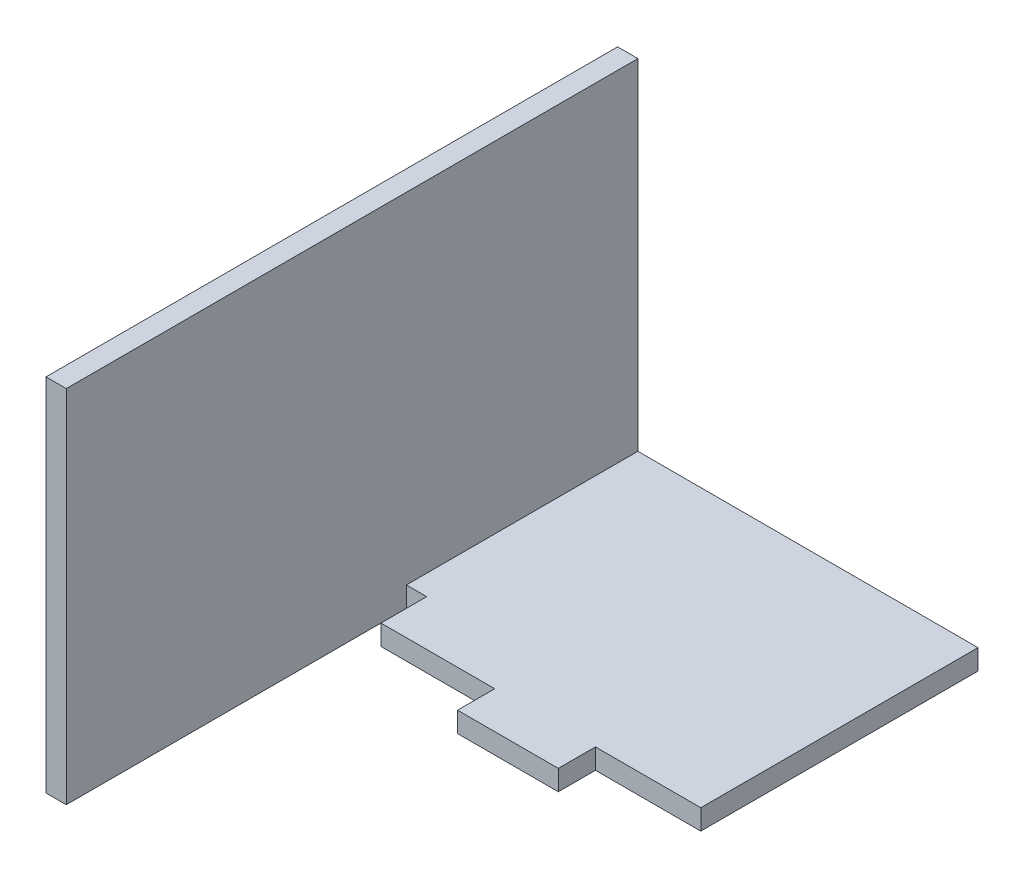
from build123d import *

# Parameters (mm, degrees)
EXTRUDE1_DEPTH     = 40
CUT_EXTRUDE3_DEPTH = 2.42


with BuildPart() as part:
    # Sketch1 → Extrude1 (new body)
    with BuildSketch(Plane.XY):
        Polygon((0, 0), (0, -25.22), (25.22, -25.22), (25.22, -23.8), (1.42, -23.8), (1.42, 0), align=None)
    extrude(amount=EXTRUDE1_DEPTH)

    # Sketch3 → Cut-Extrude3 (cut, through all)
    with BuildSketch(Plane(origin=(0, -23.8, 0), x_dir=(-1, 0, 0), z_dir=(0, 1, 0))):
        Polygon((-1.42, 40), (-1.42, 16.2), (-2.84, 16.2), (-2.84, 19.4), (-10.8, 19.4), (-10.8, 22), (-17.85, 22), (-17.85, 19.4), (-25.22, 19.4), (-25.22, 40), align=None)
    extrude(amount=-CUT_EXTRUDE3_DEPTH, mode=Mode.SUBTRACT)


solid = part.part
